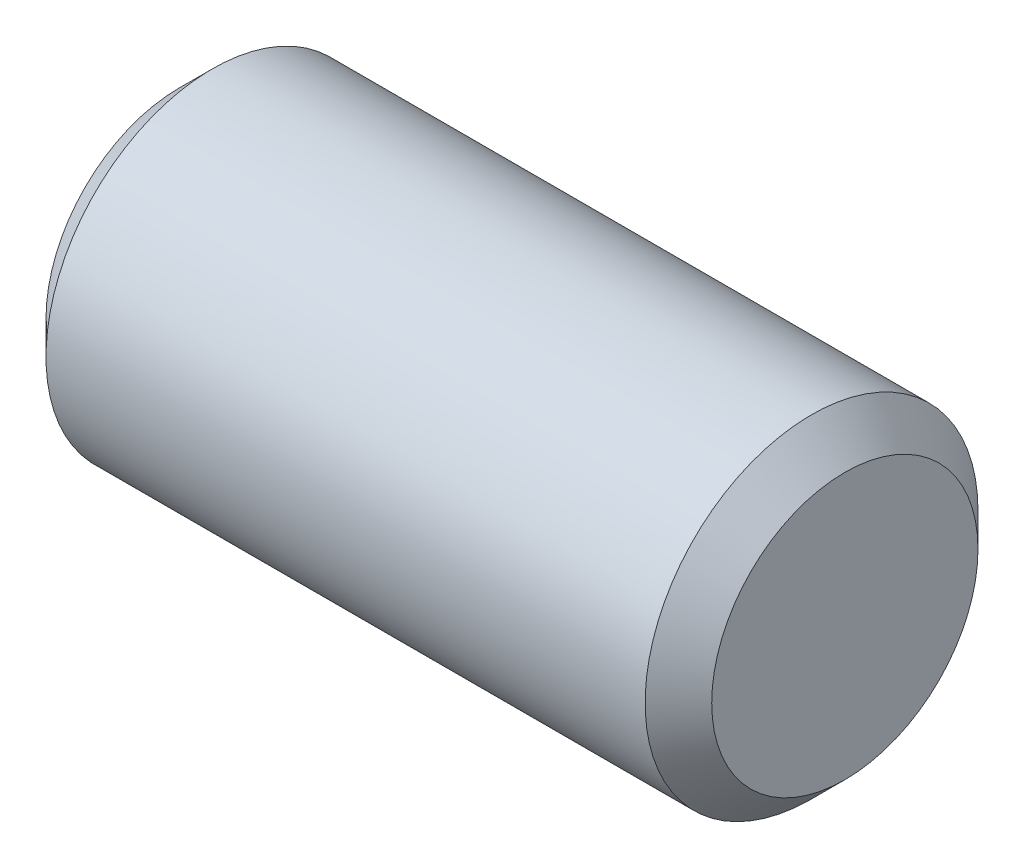
from build123d import *

# Parameters (mm, degrees)
SKETCH2_R           = 1.5875
EXTRUDE1_DEPTH      = 3.175
EXTRUDE1_DEPTH_BACK = 3.175
CHAMFER1_SIZE       = 0.3175


with BuildPart() as part:
    # Sketch2 → Extrude1 (new body, two sides)
    with BuildSketch(Plane(origin=(0, 0, 0), x_dir=(0, 0, -1), z_dir=(1, 0, 0))) as extrude1_sk:
        Circle(SKETCH2_R)
    extrude(amount=EXTRUDE1_DEPTH)
    extrude(extrude1_sk.sketch, amount=-EXTRUDE1_DEPTH_BACK)

    # Chamfer1
    chamfer1_edges = [part.edges().sort_by_distance(p)[0] for p in [
        (-3.175, 0, 1.5875),
        (3.175, 0, 1.5875),
    ]]
    chamfer(chamfer1_edges, length=CHAMFER1_SIZE)


solid = part.part
